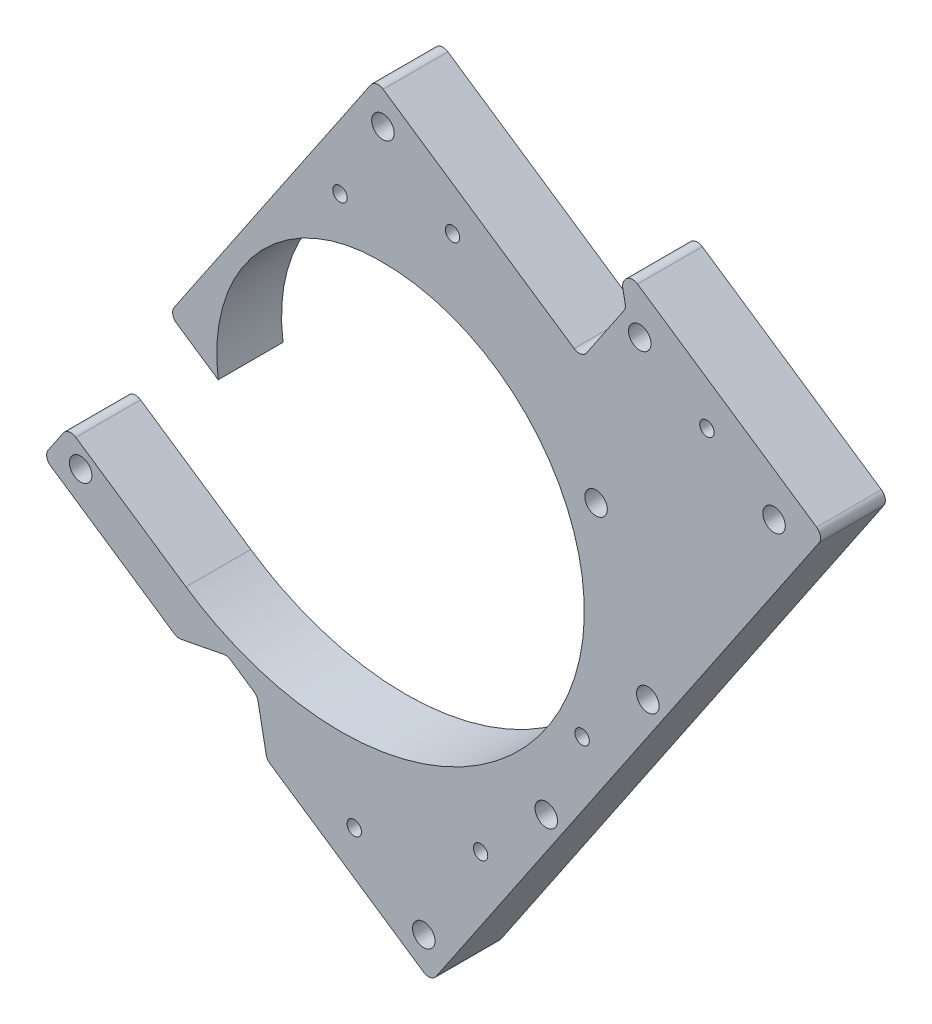
from build123d import *

# Parameters (mm, degrees)
BOSS_EXTRUDE2_DEPTH = 22.86
CUT_EXTRUDE1_DEPTH  = 23.8600001
SKETCH10_R          = 3.96875
CUT_EXTRUDE2_DEPTH  = 23.8600001
BOSS_EXTRUDE4_DEPTH = 22.86
SKETCH13_R          = 3.96875
CUT_EXTRUDE5_DEPTH  = 23.8600001
LPATTERN1_COUNT     = 2
LPATTERN1_PITCH     = 64
SKETCH14_R          = 2.54
CUT_EXTRUDE6_DEPTH  = 23.8600001
SKETCH15_R          = 3.96875
CUT_EXTRUDE7_DEPTH  = 23.8600001
SKETCH16_R          = 3.96875
CUT_EXTRUDE8_DEPTH  = 23.8600001
SKETCH19_R          = 3.96875
CUT_EXTRUDE11_DEPTH = 23.8600001
SKETCH21_R          = 2.54
CUT_EXTRUDE12_DEPTH = 23.8600001
SKETCH23_R          = 4.16785984
SKETCH23_R_2        = 4.440390953
BOSS_EXTRUDE5_DEPTH = 22.86
CUT_EXTRUDE13_DEPTH = 23.8600001
FILLET1_R           = 3.175


with BuildPart() as part:
    # Sketch6 → Boss-Extrude2 (new body)
    with BuildSketch(Plane.XY):
        with BuildLine():
            Line((-68.006850091, -76.67090114), (-109.486767671, -48.656527855))
            Line((-109.486767671, -48.656527855), (-118.371760678, -61.812230963))
            Line((-118.371760678, -61.812230963), (18.447551645, -154.216158235))
            Line((18.447551645, -154.216158235), (135.729459338, 19.43912279))
            Line((135.729459338, 19.43912279), (-1.089852986, 111.843050063))
            Line((-1.089852986, 111.843050063), (-73.946795643, 3.966284577))
            Line((-73.946795643, 3.966284577), (-56.624438948, -7.732749433))
            ThreePointArc((-56.624438948, -7.732749433), (-43.058385537, 37.577891571), (0, 57.15))
            ThreePointArc((0, 57.15), (56.404848571, 31.095576642), (70.829334649, -29.338471048))
            add(Edge.make_bspline(
                [(70.829334649, -29.338471048), (70.811686062, -29.418295928), (70.776015112, -29.578104383), (70.713320217, -29.85478305), (70.619021771, -30.262929245), (70.501052001, -30.762086912), (70.364034474, -31.322191481), (70.199318515, -31.970958926), (70.000453855, -32.723919765), (69.795103485, -33.469783355), (69.582015398, -34.214296028), (69.361377803, -34.956693289), (69.133257682, -35.696762218), (68.838782679, -36.61892651), (68.470566207, -37.720710028), (68.019498024, -38.998776477), (67.474836154, -40.448808619), (66.901337925, -41.887676852), (66.299328392, -43.31485223), (65.669141732, -44.729810424), (65.011119088, -46.132040323), (64.325609411, -47.52103904), (63.612968547, -48.896314904), (62.87355937, -50.257385735), (62.107751613, -51.603779381), (61.315921169, -52.935034173), (60.49845004, -54.250698756), (59.655726138, -55.550331897), (58.571247582, -57.154294757), (57.220953058, -59.045283389), (55.576035723, -61.200397094), (53.604026134, -63.590264702), (51.54329346, -65.904053004), (49.39728314, -68.138962994), (47.169496434, -70.29235602), (44.863486103, -72.361752995), (42.482847363, -74.344831806), (40.031215607, -76.239428526), (36.882516177, -78.494556171), (32.976808929, -81.016011003), (28.250788286, -83.68089187), (21.41551215, -86.919136497), (14.30829026, -89.526654921), (6.996956895, -91.488176442), (-0.451922312, -92.797413176), (-6.61686174, -93.456358442), (-12.81195397, -93.702029749), (-19.009644204, -93.537285056), (-25.183124422, -92.966685286), (-31.306438312, -91.996382122), (-36.598524037, -90.804323442), (-41.072542301, -89.543185606), (-44.752319298, -88.33589156), (-47.664184976, -87.27761875), (-50.541347258, -86.128353728), (-53.381128552, -84.889612663), (-56.180924218, -83.562977818), (-58.593536599, -82.326710176), (-60.633378351, -81.214215821), (-62.313751085, -80.252471782), (-63.646071553, -79.462491566), (-64.966093336, -78.652178853), (-66.222359154, -77.854259082), (-67.143044791, -77.250601571), (-67.736251212, -76.85365602), (-68.006850091, -76.67090114)],
                knots=[0.071020771, 0.071020771, 0.071020771, 0.071020771, 0.071020771, 0.072848477, 0.074676184, 0.07650389, 0.078331597, 0.08198701, 0.085642423, 0.089297836, 0.092953249, 0.096608662, 0.100264075, 0.103919488, 0.107574901, 0.114885727, 0.122196554, 0.12950738, 0.136818214, 0.144129048, 0.151439882, 0.158750716, 0.166061558, 0.173372401, 0.180683243, 0.187994085, 0.195304924, 0.202615763, 0.209926602, 0.217237441, 0.231859103, 0.246480766, 0.261102426, 0.275724085, 0.290345754, 0.304967424, 0.319589099, 0.334210774, 0.348832457, 0.36345414, 0.392697464, 0.421940789, 0.451184112, 0.506140643, 0.535383973, 0.564627303, 0.593870641, 0.623113979, 0.652357319, 0.68160066, 0.710843985, 0.740087309, 0.754708984, 0.769330659, 0.783952333, 0.798574008, 0.813195669, 0.82781733, 0.842438991, 0.849749821, 0.857060652, 0.86437149, 0.871682327, 0.878993165, 0.885158103, 0.885158103, 0.885158103, 0.885158103, 0.885158103], degree=4))
        make_face()
    extrude(amount=BOSS_EXTRUDE2_DEPTH)

    # Sketch8 → Cut-Extrude1 (cut, through all)
    with BuildSketch(Plane.XY.offset(22.86)):
        Polygon((-71.011229489, -93.798205788), (-53.378672597, -90.381637707), (-42.854110111, -97.489632113), (-39.43754203, -115.122189004), align=None)
    extrude(amount=-CUT_EXTRUDE1_DEPTH, mode=Mode.SUBTRACT)

    # Sketch10 → Cut-Extrude2 (cut, through all)
    with BuildSketch(Plane.XY.offset(22.86)):
        with Locations((4.996496209, -84.796642912)):
            Circle(SKETCH10_R)
        with Locations((40.816310536, -31.759477627)):
            Circle(SKETCH10_R)
        with Locations((76.636124864, 21.277687659)):
            Circle(SKETCH10_R)
        with Locations((-45.295165913, -45.214466102)):
            Circle(SKETCH10_R)
    extrude(amount=-CUT_EXTRUDE2_DEPTH, mode=Mode.SUBTRACT)

    # Sketch12 → Boss-Extrude4 (add, through all)
    with BuildSketch(Plane.XY.offset(22.86)):
        Polygon((135.729459338, 19.43912279), (67.319803176, 65.641086427), (88.643786393, 97.214773886), (157.053442554, 51.01281025), align=None)
    extrude(amount=-BOSS_EXTRUDE4_DEPTH)

    # Sketch13 → Cut-Extrude5 (cut, through all)
    with BuildSketch(Plane.XY.offset(22.86)):
        with Locations((94.899221836, -29.671127724)):
            Circle(SKETCH13_R)
    cut_extrude5 = extrude(amount=-CUT_EXTRUDE5_DEPTH, mode=Mode.SUBTRACT)

    # LPattern1: Cut-Extrude5 ×2
    with Locations(*[Vector(-0.559684599, -0.828705708, 0) * (i * LPATTERN1_PITCH) for i in range(1, LPATTERN1_COUNT)]):
        add(cut_extrude5, mode=Mode.SUBTRACT)

    # Sketch14 → Cut-Extrude6 (cut, through all)
    with BuildSketch(Plane.XY.offset(22.86)):
        with Locations((71.72703343, -52.635713164)):
            Circle(SKETCH14_R)
        with Locations((35.907219102, -105.67287845)):
            Circle(SKETCH14_R)
        with Locations((115.740620068, 63.589229581)):
            Circle(SKETCH14_R)
    extrude(amount=-CUT_EXTRUDE6_DEPTH, mode=Mode.SUBTRACT)

    # Sketch15 → Cut-Extrude7 (cut, through all)
    with BuildSketch(Plane.XY.offset(22.86)):
        with Locations((-105.147343009, -59.249804902)):
            Circle(SKETCH15_R)
        with Locations((15.885125585, -140.991740566)):
            Circle(SKETCH15_R)
        with Locations((1.472573075, 98.618632394)):
            Circle(SKETCH15_R)
    extrude(amount=-CUT_EXTRUDE7_DEPTH, mode=Mode.SUBTRACT)

    # Sketch16 → Cut-Extrude8 (cut, through all)
    with BuildSketch(Plane.XY.offset(22.86)):
        with Locations((92.060354474, 79.582216994)):
            Circle(SKETCH16_R)
        with Locations((139.420885662, 47.596242169)):
            Circle(SKETCH16_R)
    extrude(amount=-CUT_EXTRUDE8_DEPTH, mode=Mode.SUBTRACT)

    # Sketch19 → Cut-Extrude11 (cut, through all)
    with BuildSketch(Plane.XY.offset(22.86)):
        with Locations((-65.680233685, -85.904783923)):
            Circle(SKETCH19_R)
    extrude(amount=-CUT_EXTRUDE11_DEPTH, mode=Mode.SUBTRACT)

    # Sketch21 → Cut-Extrude12 (cut, through all)
    with BuildSketch(Plane.XY.offset(22.86)):
        with Locations((-13.666272317, 70.530227577)):
            Circle(SKETCH21_R)
        with Locations((26.00698069, 78.217505758)):
            Circle(SKETCH21_R)
        with Locations((-86.729358658, -71.688795112)):
            Circle(SKETCH21_R)
        with Locations((-8.64928203, -120.590613931)):
            Circle(SKETCH21_R)
    extrude(amount=-CUT_EXTRUDE12_DEPTH, mode=Mode.SUBTRACT)

    # Sketch23 → Boss-Extrude5 (add, through all)
    with BuildSketch(Plane.XY.offset(22.86)):
        with Locations((-65.680233685, -85.904783923)):
            Circle(SKETCH23_R)
        with Locations((-86.729358658, -71.688795112)):
            Circle(SKETCH23_R_2)
    extrude(amount=-BOSS_EXTRUDE5_DEPTH)

    # Sketch25 → Cut-Extrude13 (cut, through all)
    with BuildSketch(Plane.XY.offset(22.86)):
        Polygon((85.800588631, 93.004948891), (87.167215863, 85.951926135), (71.529628171, 62.797888664), (67.319803176, 65.641086427), align=None)
    extrude(amount=-CUT_EXTRUDE13_DEPTH, mode=Mode.SUBTRACT)

    # Fillet1
    fillet1_edges = [part.edges().sort_by_distance(p)[0] for p in [
        (-73.946795643, 3.966284577, 11.43),
        (-1.089852986, 111.843050063, 11.43),
        (18.447551645, -154.216158235, 11.43),
        (-118.371760678, -61.812230963, 11.43),
        (-109.486767671, -48.656527855, 11.43),
        (85.800588631, 93.004948891, 11.43),
        (87.167215863, 85.951926135, 11.43),
        (71.529628171, 62.797888664, 11.43),
        (-39.43754203, -115.122189004, 11.43),
        (-71.011229489, -93.798205788, 11.43),
        (-53.378672597, -90.381637707, 11.43),
        (-42.854110111, -97.489632113, 11.43),
        (157.053442554, 51.01281025, 11.43),
        (88.643786393, 97.214773886, 11.43),
    ]]
    fillet(fillet1_edges, radius=FILLET1_R)


solid = part.part
